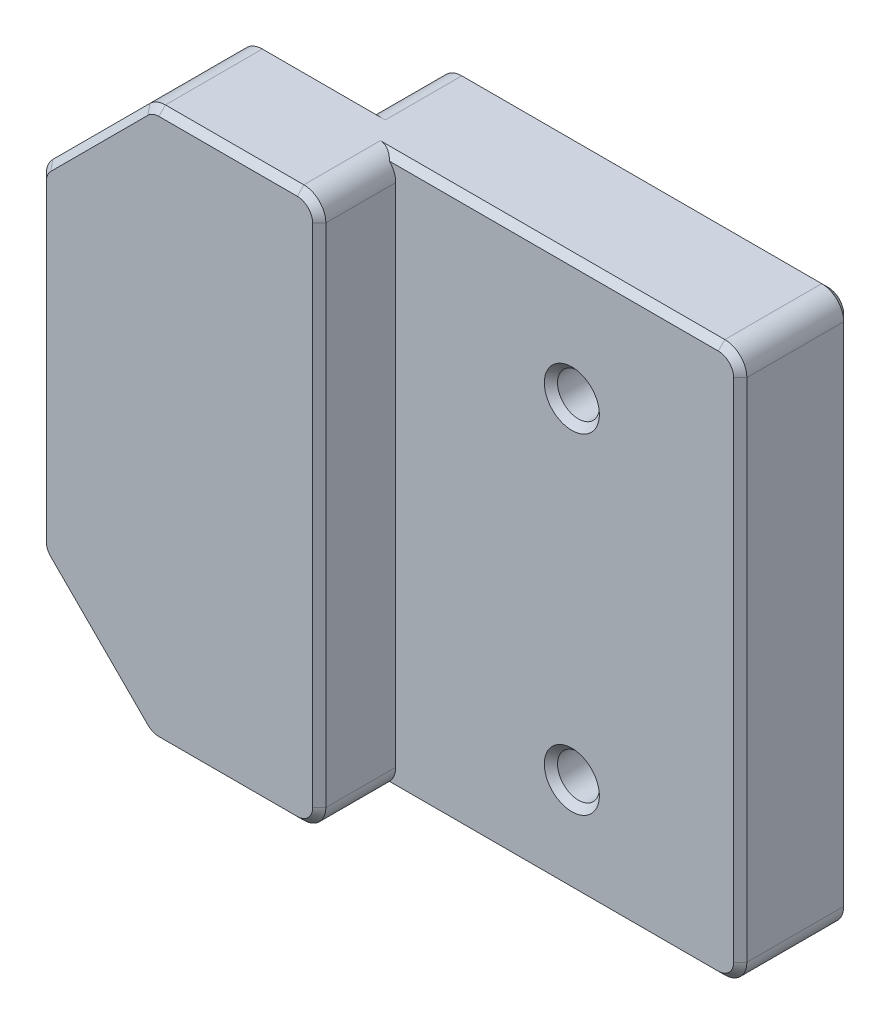
from build123d import *

# Parameters (mm, degrees)
BOSS_EXTRUDE1_DEPTH = 25
SKETCH2_R           = 0.95
CUT_EXTRUDE1_DEPTH  = 25
CHAMFER1_SIZE       = 5
FILLET1_R           = 1
CHAMFER2_SIZE       = 0.3


with BuildPart() as part:
    # Sketch1 → Boss-Extrude1 (new body)
    with BuildSketch(Plane(origin=(0, 0, 0), x_dir=(1, 0, 0), z_dir=(0, 1, 0))):
        Polygon((0, 0), (-18.35, 0), (-18.35, -3.475), (-28.35, -3.475), (-28.35, -8.475), (-15.65, -8.475), (-15.65, -5), (0, -5), align=None)
    extrude(amount=BOSS_EXTRUDE1_DEPTH)

    # Sketch2 → Cut-Extrude1 (cut)
    with BuildSketch(Plane.XY.offset(5)):
        with Locations((-7.65, 4.5)):
            Circle(SKETCH2_R)
        with Locations((-7.65, 19.5)):
            Circle(SKETCH2_R)
    extrude(amount=-CUT_EXTRUDE1_DEPTH, mode=Mode.SUBTRACT)

    # Chamfer1
    chamfer1_edges = [part.edges().sort_by_distance(p)[0] for p in [
        (-28.35, 25, 5.975),
        (-28.35, 0, 5.975),
    ]]
    chamfer(chamfer1_edges, length=CHAMFER1_SIZE)

    # Fillet1
    fillet1_edges = [part.edges().sort_by_distance(p)[0] for p in [
        (-18.35, 0, 1.7375),
        (0, 0, 2.5),
        (-18.35, 25, 1.7375),
        (-15.65, 25, 6.7375),
        (-28.35, 20, 5.975),
        (-28.35, 5, 5.975),
        (-23.35, 0, 5.975),
        (-23.35, 25, 5.975),
        (0, 25, 2.5),
        (-15.65, 0, 6.7375),
    ]]
    fillet(fillet1_edges, radius=FILLET1_R)

    # Chamfer2
    chamfer2_edges = [part.edges().sort_by_distance(p)[0] for p in [
        (-20.642893219, 0, 3.475),
        (-20.642893219, 25, 3.475),
        (-8.6, 4.5, 0),
        (-8.6, 4.5, 5),
        (-8.6, 19.5, 0),
        (-8.6, 19.5, 5),
        (-8.325, 25, 5),
        (-19.792893219, 25, 8.475),
        (-9.175, 25, 0),
        (-15.65, 12.5, 8.475),
        (-28.35, 12.5, 8.475),
        (-25.85, 2.5, 8.475),
        (-19.792893219, 0, 8.475),
        (-25.85, 22.5, 8.475),
        (-28.273879533, 5.03153013, 8.475),
        (-23.31846987, 0.076120467, 8.475),
        (-15.942893219, 0.292893219, 8.475),
        (-28.273879533, 19.96846987, 8.475),
        (-23.31846987, 24.923879533, 8.475),
        (-15.942893219, 24.707106781, 8.475),
        (-25.85, 22.5, 3.475),
        (-25.85, 2.5, 3.475),
        (-28.35, 12.5, 3.475),
        (-28.273879533, 5.03153013, 3.475),
        (-23.31846987, 0.076120467, 3.475),
        (-28.273879533, 19.96846987, 3.475),
        (-23.31846987, 24.923879533, 3.475),
        (-9.175, 0, 0),
        (-18.35, 12.5, 0),
        (0, 12.5, 0),
        (-0.292893219, 0.292893219, 0),
        (-18.057106781, 0.292893219, 0),
        (-18.057106781, 24.707106781, 0),
        (-0.292893219, 24.707106781, 0),
        (0, 12.5, 5),
        (-0.292893219, 0.292893219, 5),
        (-0.292893219, 24.707106781, 5),
        (-8.325, 0, 5),
    ]]
    chamfer(chamfer2_edges, length=CHAMFER2_SIZE)


solid = part.part
